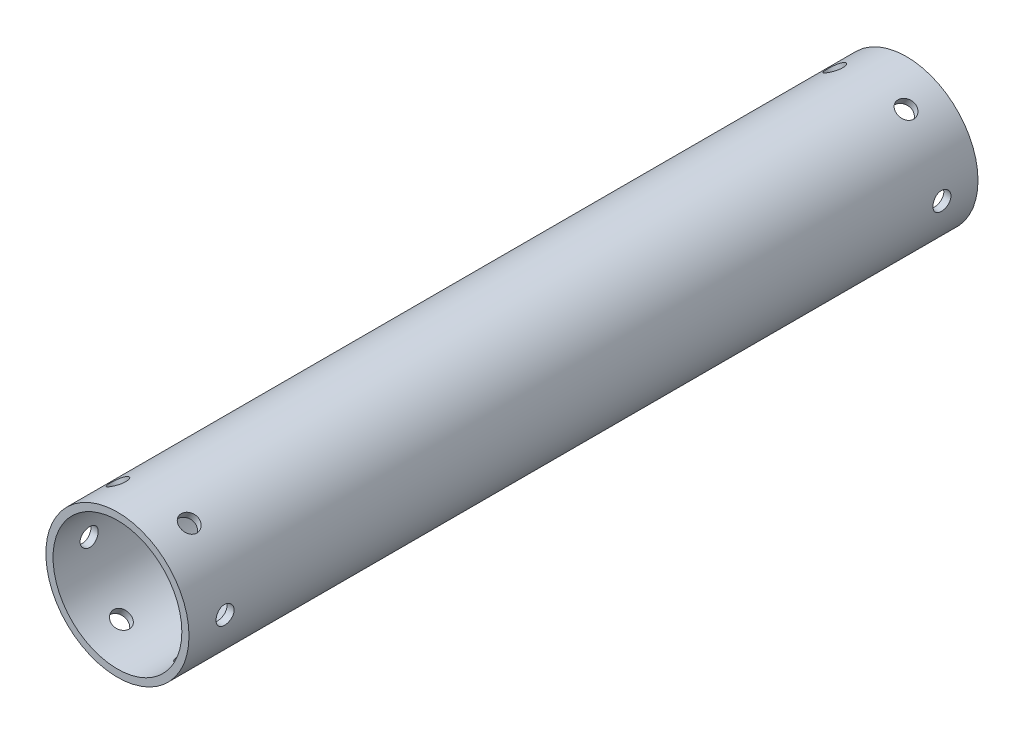
from build123d import *

# Parameters (mm, degrees)
ESBO_O1_R                = 31.75
ESBO_O1_R_2              = 28.575
RESSALTO_EXTRUS_O1_DEPTH = 350
ESBO_O3_R                = 4
CORTE_EXTRUS_O1_DEPTH    = 45
PADR_OCIRCULAR1_COUNT    = 6


with BuildPart() as part:
    # Esboço1 → Ressalto-extrusão1 (new body)
    with BuildSketch(Plane.XY):
        Circle(ESBO_O1_R)
        Circle(ESBO_O1_R_2, mode=Mode.SUBTRACT)
    extrude(amount=RESSALTO_EXTRUS_O1_DEPTH)

    # Esboço3 → Corte-extrusão1 (cut)
    with BuildSketch(Plane(origin=(0, 0, 0), x_dir=(0, 0, -1), z_dir=(1, 0, 0))):
        with Locations((-16, 0)):
            Circle(ESBO_O3_R)
        with Locations((-334, 0)):
            Circle(ESBO_O3_R)
    corte_extrus_o1 = extrude(amount=-CORTE_EXTRUS_O1_DEPTH, mode=Mode.SUBTRACT)

    # PadrãoCircular1: Corte-extrusão1 ×6 about axis
    padr_ocircular1_axis = Axis((0, 0, 350), (0, 0, -1))
    for i in range(1, PADR_OCIRCULAR1_COUNT):
        add(corte_extrus_o1.rotate(padr_ocircular1_axis, i * 360 / PADR_OCIRCULAR1_COUNT), mode=Mode.SUBTRACT)


solid = part.part
